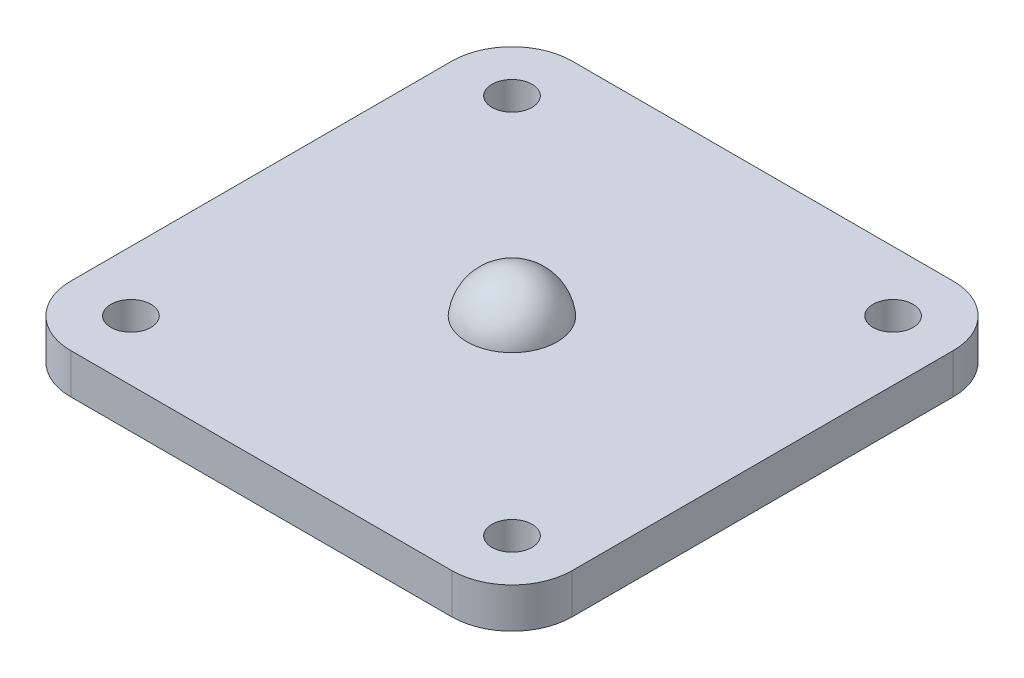
from build123d import *

# Parameters (mm, degrees)
SKETCH1_W           = 25
SKETCH1_H           = 25
BOSS_EXTRUDE1_DEPTH = 2
FILLET1_R           = 3
CUT_EXTRUDE1_REACH  = 4
SKETCH2_R           = 1


with BuildPart() as part:
    # Sketch1 → Boss-Extrude1 (new body)
    with BuildSketch(Plane(origin=(0, 0, 0), x_dir=(1, 0, 0), z_dir=(0, 1, 0))):
        Rectangle(SKETCH1_W, SKETCH1_H)
    extrude(amount=BOSS_EXTRUDE1_DEPTH)

    # Fillet1
    fillet1_edges = [part.edges().sort_by_distance(p)[0] for p in [
        (12.5, 1, 12.5),
        (-12.5, 1, 12.5),
        (-12.5, 1, -12.5),
        (12.5, 1, -12.5),
    ]]
    fillet(fillet1_edges, radius=FILLET1_R)

    # Sketch2 → Cut-Extrude1 (cut, up to next)
    with BuildSketch(Plane(origin=(0, 2, 0), x_dir=(1, 0, 0), z_dir=(0, 1, 0)), mode=Mode.PRIVATE) as cut_extrude1_sk1:
        with Locations((-9.5, 9.5)):
            Circle(SKETCH2_R)
    cut_extrude1_tool1 = extrude(cut_extrude1_sk1.sketch, amount=-CUT_EXTRUDE1_REACH, mode=Mode.PRIVATE) & part.part
    add(cut_extrude1_tool1.solids().sort_by_distance((-9.5, 2, -9.5))[0], mode=Mode.SUBTRACT)
    # Sketch2 → Cut-Extrude1 (cut, up to next)
    with BuildSketch(Plane(origin=(0, 2, 0), x_dir=(1, 0, 0), z_dir=(0, 1, 0)), mode=Mode.PRIVATE) as cut_extrude1_sk2:
        with Locations((9.5, 9.5)):
            Circle(SKETCH2_R)
    cut_extrude1_tool2 = extrude(cut_extrude1_sk2.sketch, amount=-CUT_EXTRUDE1_REACH, mode=Mode.PRIVATE) & part.part
    add(cut_extrude1_tool2.solids().sort_by_distance((9.5, 2, -9.5))[0], mode=Mode.SUBTRACT)
    # Sketch2 → Cut-Extrude1 (cut, up to next)
    with BuildSketch(Plane(origin=(0, 2, 0), x_dir=(1, 0, 0), z_dir=(0, 1, 0)), mode=Mode.PRIVATE) as cut_extrude1_sk3:
        with Locations((9.5, -9.5)):
            Circle(SKETCH2_R)
    cut_extrude1_tool3 = extrude(cut_extrude1_sk3.sketch, amount=-CUT_EXTRUDE1_REACH, mode=Mode.PRIVATE) & part.part
    add(cut_extrude1_tool3.solids().sort_by_distance((9.5, 2, 9.5))[0], mode=Mode.SUBTRACT)
    # Sketch2 → Cut-Extrude1 (cut, up to next)
    with BuildSketch(Plane(origin=(0, 2, 0), x_dir=(1, 0, 0), z_dir=(0, 1, 0)), mode=Mode.PRIVATE) as cut_extrude1_sk4:
        with Locations((-9.5, -9.5)):
            Circle(SKETCH2_R)
    cut_extrude1_tool4 = extrude(cut_extrude1_sk4.sketch, amount=-CUT_EXTRUDE1_REACH, mode=Mode.PRIVATE) & part.part
    add(cut_extrude1_tool4.solids().sort_by_distance((-9.5, 2, 9.5))[0], mode=Mode.SUBTRACT)

    # Sketch3 → Revolve1 (revolve)
    with BuildSketch(Plane.XY):
        with BuildLine():
            Line((0, 2), (0, 4))
            ThreePointArc((0, 4), (1.505199322, 3.427724238), (2.25, 2))
            Line((2.25, 2), (0, 2))
        make_face()
    revolve(axis=Axis((0, 2, 0), (0, 1, 0)))


solid = part.part
